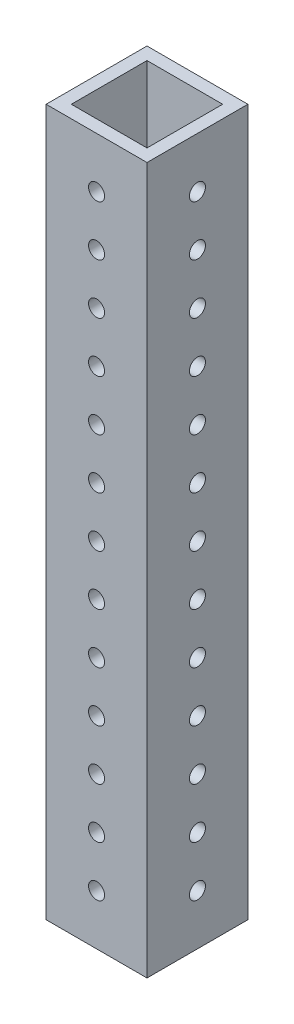
from build123d import *

# Parameters (mm, degrees)
SKETCH1_W                   = 25.4
SKETCH1_H                   = 25.4
SKETCH1_W_2                 = 19.05
SKETCH1_H_2                 = 19.05
BOSS_EXTRUDE1_DEPTH         = 177.8
F_21_0_159_DIAMETER_HOLE1_D = 4.0386
LPATTERN1_COUNT             = 13
LPATTERN1_PITCH             = 12.7
F_21_0_159_DIAMETER_HOLE2_D = 4.0386
LPATTERN2_COUNT             = 13
LPATTERN2_PITCH             = 12.7


with BuildPart() as part:
    # Sketch1 → Boss-Extrude1 (new body)
    with BuildSketch(Plane(origin=(0, 0, 0), x_dir=(1, 0, 0), z_dir=(0, 1, 0))):
        Rectangle(SKETCH1_W, SKETCH1_H)
        Rectangle(SKETCH1_W_2, SKETCH1_H_2, mode=Mode.SUBTRACT)
    extrude(amount=BOSS_EXTRUDE1_DEPTH)

    # #21 (0.159) Diameter Hole1 (through all)
    with Locations(Plane.ZY.offset(12.7)):
        with Locations((0, 12.7)):
            f_21_0_159_diameter_hole1 = Hole(F_21_0_159_DIAMETER_HOLE1_D / 2)

    # LPattern1: #21 (0.159) Diameter Hole1 ×13
    with Locations(*[(0, i * LPATTERN1_PITCH, 0) for i in range(1, LPATTERN1_COUNT)]):
        add(f_21_0_159_diameter_hole1, mode=Mode.SUBTRACT)

    # #21 (0.159) Diameter Hole2 (through all)
    with Locations(Plane(origin=(0, 0, -12.7), x_dir=(-1, 0, 0), z_dir=(0, 0, -1))):
        with Locations((0, 12.7)):
            f_21_0_159_diameter_hole2 = Hole(F_21_0_159_DIAMETER_HOLE2_D / 2)

    # LPattern2: #21 (0.159) Diameter Hole2 ×13
    with Locations(*[(0, i * LPATTERN2_PITCH, 0) for i in range(1, LPATTERN2_COUNT)]):
        add(f_21_0_159_diameter_hole2, mode=Mode.SUBTRACT)


solid = part.part
